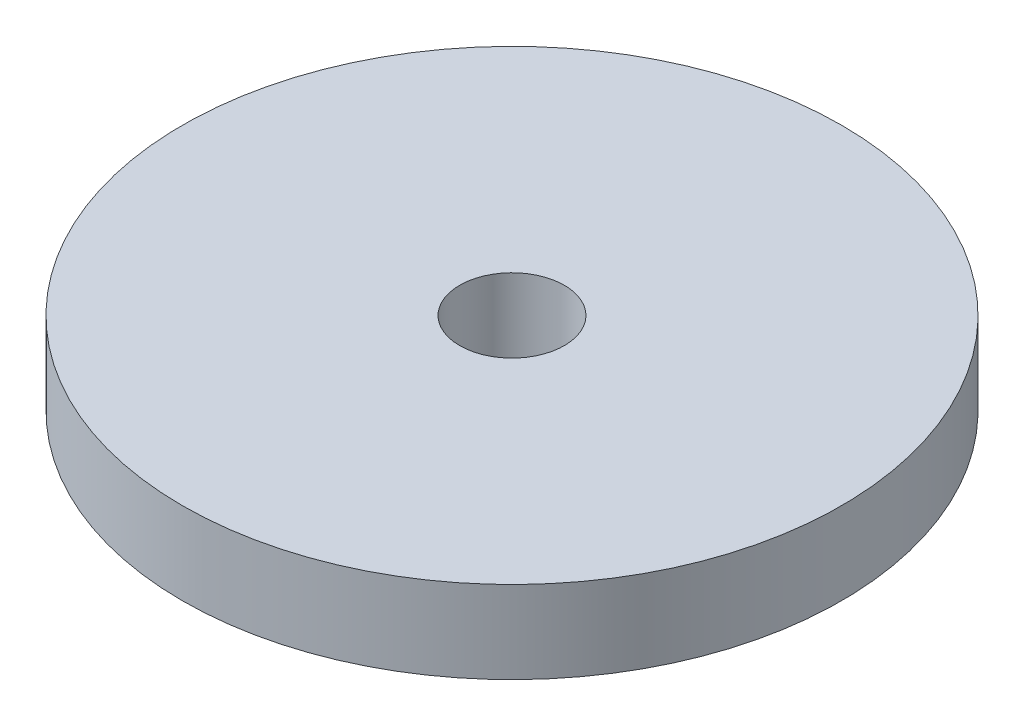
from build123d import *

# Parameters (mm, degrees)
ESQUISSE2_R        = 20
ESQUISSE2_R_2      = 3.175
BOSS_EXTRU_1_DEPTH = 5


with BuildPart() as part:
    # Esquisse2 → Boss.-Extru.1 (new body)
    with BuildSketch(Plane(origin=(0, 0, 0), x_dir=(1, 0, 0), z_dir=(0, 1, 0))):
        with Locations((-7.24145811, 12.136030241)):
            Circle(ESQUISSE2_R)
        with Locations((-7.24145811, 12.136030241)):
            Circle(ESQUISSE2_R_2, mode=Mode.SUBTRACT)
    extrude(amount=BOSS_EXTRU_1_DEPTH)


solid = part.part
